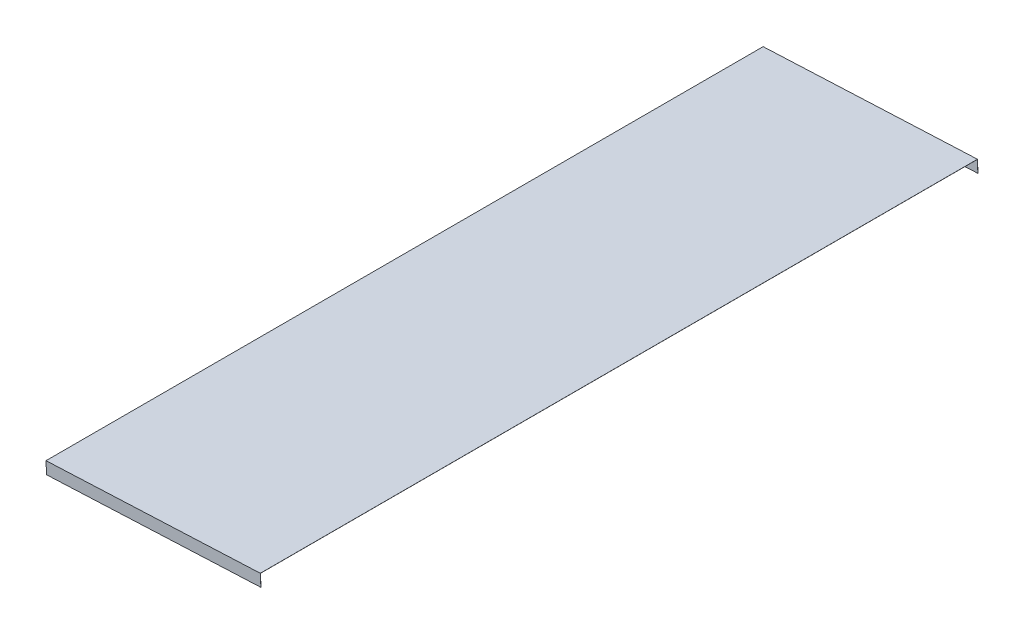
from build123d import *

# Parameters (mm, degrees)
BOSS_EXTRUDE2_DEPTH = 600
SKETCH2_W           = 179.507885947
SKETCH2_H           = 0.1
BOSS_EXTRUDE3_DEPTH = 10
SKETCH3_W           = 179.507885947
SKETCH3_H           = 0.1
BOSS_EXTRUDE4_DEPTH = 10


with BuildPart() as part:
    # Sketch1 → Boss-Extrude2 (new body)
    with BuildSketch(Plane.XY):
        Polygon((-1723.971070815, 565.254300802), (-1544.645451435, 573.341534617), (-1544.649956659, 573.44143308), (-1723.97557604, 565.354199265), align=None)
    extrude(amount=BOSS_EXTRUDE2_DEPTH)

    # Sketch2 → Boss-Extrude3 (add)
    with BuildSketch(Plane(origin=(-28.943777696, 641.796809779, 0), x_dir=(0.998984632, 0.045052248, 0), z_dir=(-0.045052248, 0.998984632, 0))):
        with Locations((-1607.000685751, -0.05)):
            Rectangle(SKETCH2_W, SKETCH2_H)
    extrude(amount=-BOSS_EXTRUDE3_DEPTH)

    # Sketch3 → Boss-Extrude4 (add)
    with BuildSketch(Plane(origin=(-28.943777696, 641.796809779, 0), x_dir=(0.998984632, 0.045052248, 0), z_dir=(-0.045052248, 0.998984632, 0))):
        with Locations((-1607.000685751, -599.95)):
            Rectangle(SKETCH3_W, SKETCH3_H)
    extrude(amount=-BOSS_EXTRUDE4_DEPTH)


solid = part.part
